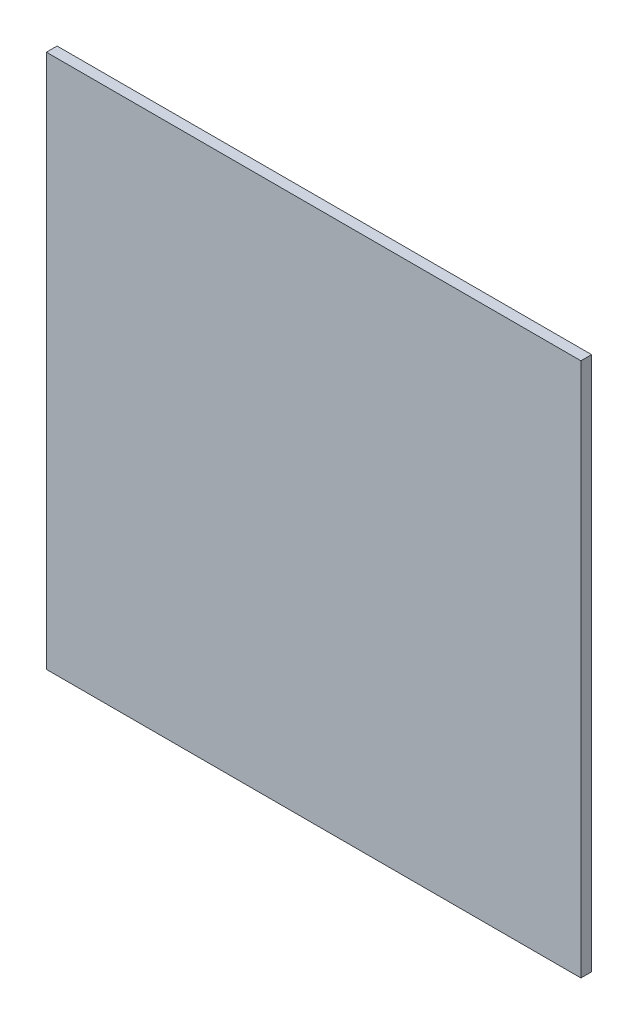
from build123d import *

# Parameters (mm, degrees)
SKIZZE1_W                       = 1000
SKIZZE1_H                       = 1000
AUFSATZ_LINEAR_AUSTRAGEN1_DEPTH = 20


with BuildPart() as part:
    # Skizze1 → Aufsatz-Linear austragen1 (new body)
    with BuildSketch(Plane.XY):
        Rectangle(SKIZZE1_W, SKIZZE1_H)
    extrude(amount=AUFSATZ_LINEAR_AUSTRAGEN1_DEPTH)


solid = part.part
